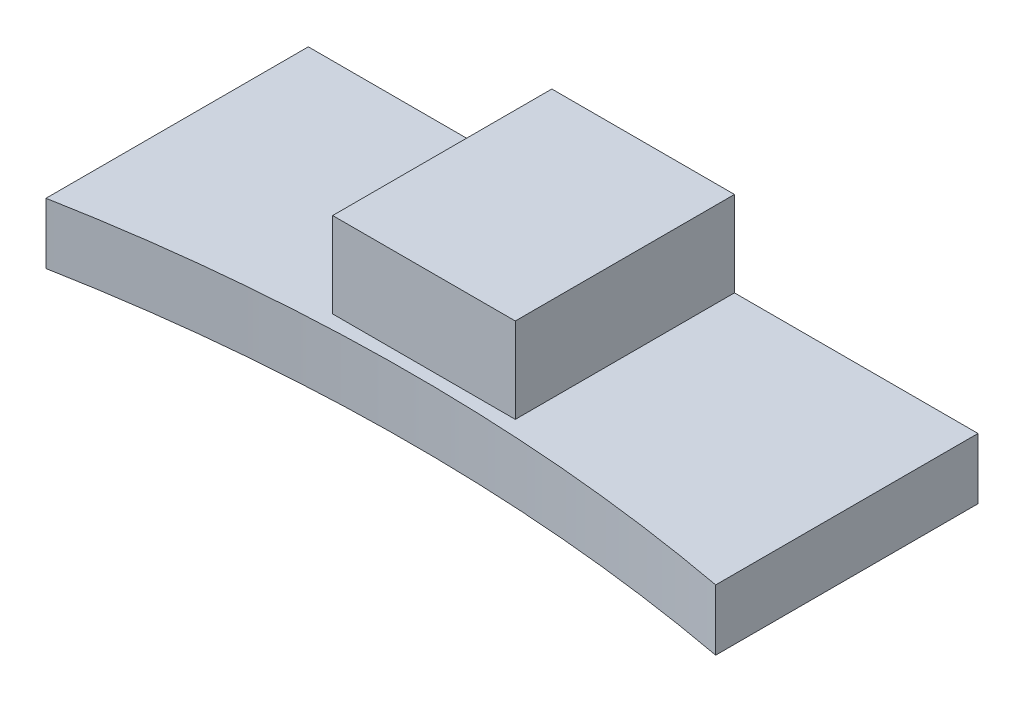
from build123d import *

# Parameters (mm, degrees)
BOSS_EXTRUDE1_DEPTH              = 5
SKETCH2_W                        = 15
SKETCH2_H                        = 18
BOSS_EXTRUDE2_DEPTH              = 7
SKETCH3_R                        = 4.5
CUT_EXTRUDE2_DEPTH               = 4
TAP_DRILL_FOR_M8X1_25_TAP1_D     = 6.8
TAP_DRILL_FOR_M8X1_25_TAP1_DEPTH = 8


with BuildPart() as part:
    # Sketch1 → Boss-Extrude1 (new body)
    with BuildSketch(Plane(origin=(0, 0, 0), x_dir=(1, 0, 0), z_dir=(0, 1, 0))):
        with BuildLine():
            Line((0, 0), (0, 21.542378969))
            Line((0, 21.542378969), (55, 21.542378969))
            Line((55, 21.542378969), (55, 0))
            ThreePointArc((55, 0), (27.5, 2.542378969), (0, 0))
        make_face()
    extrude(amount=BOSS_EXTRUDE1_DEPTH)

    # Sketch2 → Boss-Extrude2 (add)
    with BuildSketch(Plane(origin=(0, 5, 0), x_dir=(1, 0, 0), z_dir=(0, 1, 0))):
        with Locations((27.5, 12.542378969)):
            Rectangle(SKETCH2_W, SKETCH2_H)
    extrude(amount=BOSS_EXTRUDE2_DEPTH)

    # Sketch3 → Cut-Extrude2 (cut)
    with BuildSketch(Plane(origin=(0, 0, -21.542378969), x_dir=(-1, 0, 0), z_dir=(0, 0, -1))):
        with Locations((-27.5, 6.5)):
            Circle(SKETCH3_R)
    extrude(amount=-CUT_EXTRUDE2_DEPTH, mode=Mode.SUBTRACT)

    # Tap Drill for M8x1.25 Tap1
    with Locations(Plane(origin=(0, 0, -17.542378969), x_dir=(-1, 0, 0), z_dir=(0, 0, -1))):
        with Locations((-27.5, 6.5)):
            Hole(TAP_DRILL_FOR_M8X1_25_TAP1_D / 2, depth=TAP_DRILL_FOR_M8X1_25_TAP1_DEPTH)


solid = part.part
